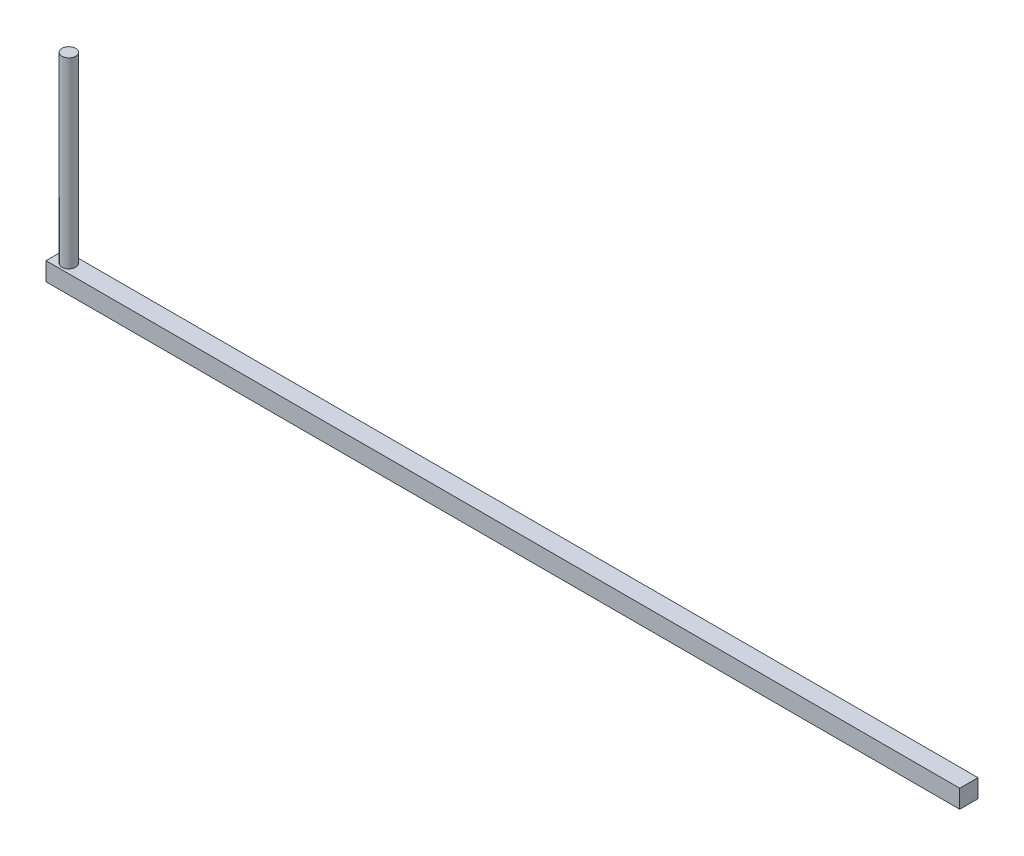
from build123d import *

# Parameters (mm, degrees)
SKETCH1_W           = 1000
SKETCH1_H           = 20
BOSS_EXTRUDE1_DEPTH = 20
SKETCH2_R           = 7.5
BOSS_EXTRUDE2_DEPTH = 200


with BuildPart() as part:
    # Sketch1 → Boss-Extrude1 (new body)
    with BuildSketch(Plane(origin=(0, 0, 0), x_dir=(1, 0, 0), z_dir=(0, 1, 0))):
        Rectangle(SKETCH1_W, SKETCH1_H)
    extrude(amount=BOSS_EXTRUDE1_DEPTH)

    # Sketch2 → Boss-Extrude2 (add)
    with BuildSketch(Plane(origin=(0, 20, 0), x_dir=(1, 0, 0), z_dir=(0, 1, 0))):
        with Locations((-485, 0)):
            Circle(SKETCH2_R)
    extrude(amount=BOSS_EXTRUDE2_DEPTH)


solid = part.part
